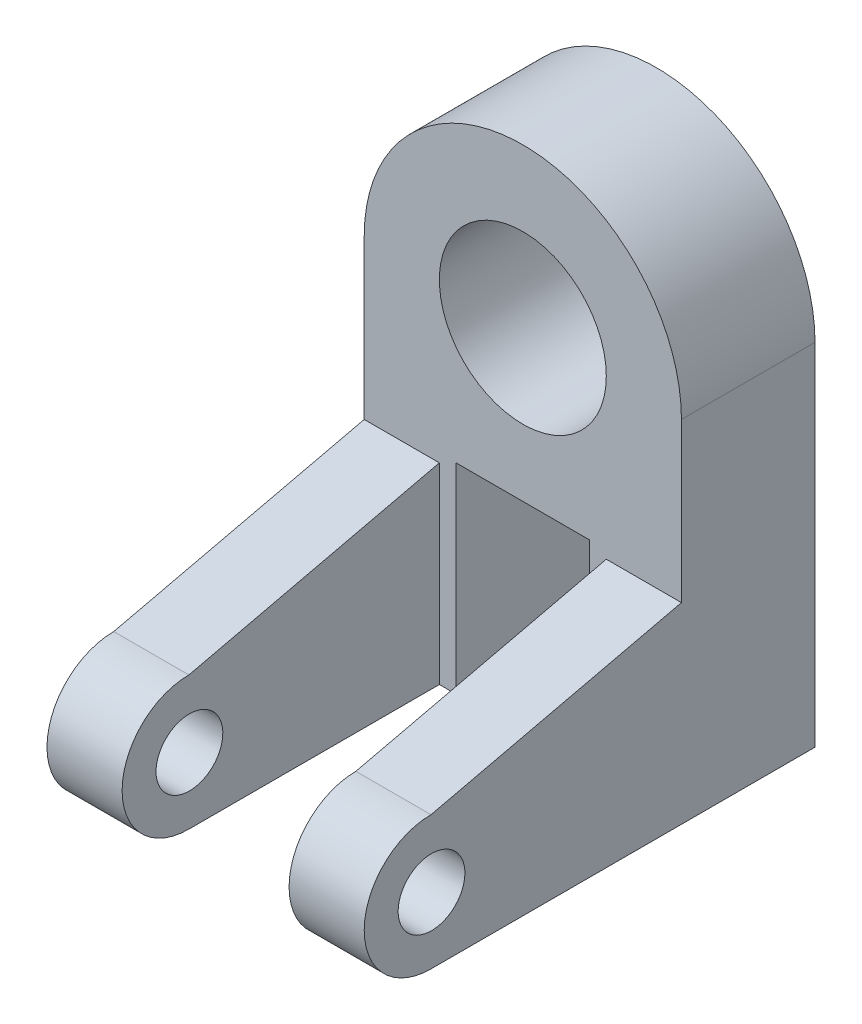
from build123d import *

# Parameters (mm, degrees)
BOSS_EXTRUDE1_DEPTH    = 32
SKETCH2_R              = 20
CUT_EXTRUDE1_DEPTH     = 33
BOSS_EXTRUDE2_DEPTH    = 18
F_16_0MM_DOWEL_SLOT1_D = 16


with BuildPart() as part:
    # Sketch1 → Boss-Extrude1 (new body)
    with BuildSketch(Plane.XY):
        with BuildLine():
            Line((-38, 0), (-38, -84))
            Line((-38, -84), (-16, -84))
            Line((-16, -84), (-16, -36))
            Line((-16, -36), (16, -36))
            Line((16, -36), (16, -84))
            Line((16, -84), (38, -84))
            Line((38, -84), (38, 0))
            ThreePointArc((38, 0), (0, 38), (-38, 0))
        make_face()
    extrude(amount=BOSS_EXTRUDE1_DEPTH)

    # Sketch2 → Cut-Extrude1 (cut, through all)
    with BuildSketch(Plane.XY.offset(32)):
        Circle(SKETCH2_R)
    extrude(amount=-CUT_EXTRUDE1_DEPTH, mode=Mode.SUBTRACT)

    # Sketch3 → Boss-Extrude2 (add)
    with BuildSketch(Plane.ZY.offset(38)):
        with BuildLine():
            Line((32, -84), (92, -84))
            ThreePointArc((92, -84), (108, -68), (92, -52))
            Line((92, -52), (32, -38))
            Line((32, -38), (32, -84))
        make_face()
    boss_extrude2 = extrude(amount=-BOSS_EXTRUDE2_DEPTH)

    # Mirror1: Boss-Extrude2 across plane
    add(boss_extrude2.mirror(Plane(origin=(0, 0, 0), x_dir=(0, 0, 1), z_dir=(1, 0, 0))))

    # Ø16.0mm Dowel Slot1 (through all)
    with Locations(Plane.ZY.offset(38)):
        with Locations((91.877349946, -68.13604901)):
            Hole(F_16_0MM_DOWEL_SLOT1_D / 2)


solid = part.part
